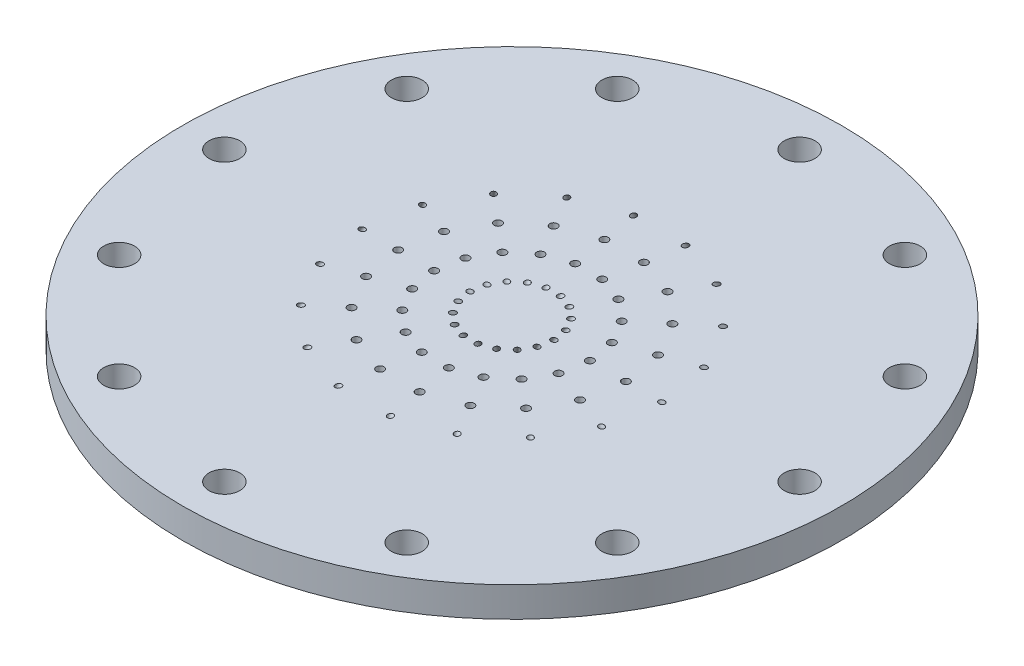
from build123d import *

# Parameters (mm, degrees)
SKETCH1_R           = 69.85
BOSS_EXTRUDE1_DEPTH = 6.35
SKETCH4_R           = 0.59055
CUT_EXTRUDE1_DEPTH  = 49.26
CUT_EXTRUDE2_START  = -51.8
SKETCH6_R           = 0.59055
CUT_EXTRUDE2_DEPTH  = 77.349261314
LOX_START           = -7.35
SKETCH7_R           = 0.8255
LOX_HOLES_DEPTH     = 8.35
CIRPATTERN1_COUNT   = 18
SKETCH8_R           = 3.2639
CUT_EXTRUDE4_DEPTH  = 7.35
CIRPATTERN2_COUNT   = 12


with BuildPart() as part:
    # Sketch1 → Boss-Extrude1 (new body)
    with BuildSketch(Plane(origin=(0, 0, 0), x_dir=(1, 0, 0), z_dir=(0, 1, 0))):
        Circle(SKETCH1_R)
    extrude(amount=BOSS_EXTRUDE1_DEPTH)

    # Sketch4 → Cut-Extrude1 (cut, through all)
    with BuildSketch(Plane(origin=(-3.917869343, -6.785948759, 0), x_dir=(-0.866025404, 0.5, 0), z_dir=(0.5, 0.866025404, 0))):
        with Locations((-4.52396584, 0)):
            Circle(SKETCH4_R)
    cut_extrude1 = extrude(amount=CUT_EXTRUDE1_DEPTH, mode=Mode.SUBTRACT)

    # Sketch6 → Cut-Extrude2 (cut)
    with BuildSketch(Plane(origin=(5.187869343, -8.985653285, 0), x_dir=(0.866025404, 0.5, 0), z_dir=(0.5, -0.866025404, 0)).offset(CUT_EXTRUDE2_START)):
        with Locations((30.67130657, 0)):
            Circle(SKETCH6_R)
    cut_extrude2 = extrude(amount=CUT_EXTRUDE2_DEPTH, mode=Mode.SUBTRACT)

    # Sketch7 → LOx Holes (cut)
    with BuildSketch(Plane(origin=(0, 6.35, 0), x_dir=(1, 0, 0), z_dir=(0, 1, 0)).offset(LOX_START)):
        with Locations((24.13, 0)):
            Circle(SKETCH7_R)
        with Locations((16.51, 0)):
            Circle(SKETCH7_R)
    lox_holes = extrude(amount=LOX_HOLES_DEPTH, mode=Mode.SUBTRACT)

    # CirPattern1: Cut-Extrude1, Cut-Extrude2, LOx Holes ×18 about axis
    cirpattern1_axis = Axis((0, 0, 0), (0, 1, 0))
    for i in range(1, CIRPATTERN1_COUNT):
        add(cut_extrude1.rotate(cirpattern1_axis, i * 360 / CIRPATTERN1_COUNT), mode=Mode.SUBTRACT)
        add(cut_extrude2.rotate(cirpattern1_axis, i * 360 / CIRPATTERN1_COUNT), mode=Mode.SUBTRACT)
        add(lox_holes.rotate(cirpattern1_axis, i * 360 / CIRPATTERN1_COUNT), mode=Mode.SUBTRACT)

    # Sketch8 → Cut-Extrude4 (cut, through all)
    with BuildSketch(Plane.XZ):
        with Locations((-60.96, 0)):
            Circle(SKETCH8_R)
    cut_extrude4 = extrude(amount=-CUT_EXTRUDE4_DEPTH, mode=Mode.SUBTRACT)

    # CirPattern2: Cut-Extrude4 ×12 about axis
    cirpattern2_axis = Axis((0, 0, 0), (0, 1, 0))
    for i in range(1, CIRPATTERN2_COUNT):
        add(cut_extrude4.rotate(cirpattern2_axis, i * 360 / CIRPATTERN2_COUNT), mode=Mode.SUBTRACT)


solid = part.part
